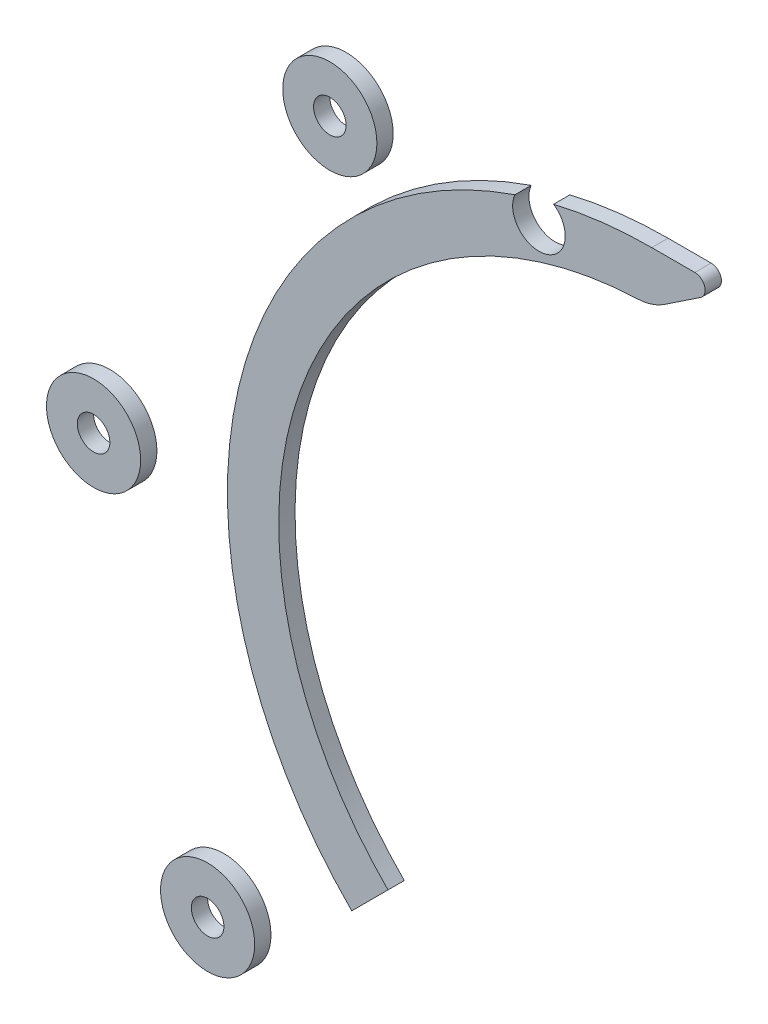
from build123d import *

# Parameters (mm, degrees)
BOSS_EXTRUDE1_DEPTH   = 3.175
SKETCH1_R             = 9.175
SKETCH1_R_2           = 3.175
BOSS_EXTRUDE1_2_DEPTH = 3.175
BOSS_EXTRUDE1_3_DEPTH = 3.175
BOSS_EXTRUDE1_4_DEPTH = 3.175
SKETCH3_R             = 5.125
CUT_EXTRUDE1_DEPTH    = 10
BOSS_EXTRUDE2_DEPTH   = 3.175
FILLET1_R             = 10
FILLET2_R             = 2


with BuildPart() as part:
    # Sketch1 → Boss-Extrude1 (new body)
    with BuildSketch(Plane.XY):
        with BuildLine():
            ThreePointArc((-51.423758408, -51.423758408), (-67.188378251, 27.830337505), (0, 72.724176569))
            Line((0, 72.724176569), (0, 82.724176569))
            ThreePointArc((0, 82.724176569), (-76.427173576, 31.657171829), (-58.49482622, -58.49482622))
            Line((-58.49482622, -58.49482622), (-51.423758408, -51.423758408))
        make_face()
    extrude(amount=-BOSS_EXTRUDE1_DEPTH)

    # Sketch3 → Cut-Extrude1 (cut)
    with BuildSketch(Plane(origin=(0, 0, -3.175), x_dir=(-1, 0, 0), z_dir=(0, 0, -1))):
        with Locations((22, 76.224176569)):
            Circle(SKETCH3_R)
    extrude(amount=-CUT_EXTRUDE1_DEPTH, mode=Mode.SUBTRACT)

    # Sketch4 → Boss-Extrude2 (add)
    with BuildSketch(Plane.XY):
        Polygon((0, 82.724176569), (15, 82.724176569), (0, 72.724176569), align=None)
    extrude(amount=-BOSS_EXTRUDE2_DEPTH)

    # Fillet1
    fillet1_edges = [part.edges().sort_by_distance(p)[0] for p in [
        (0, 72.724176569, -1.5875),
    ]]
    fillet(fillet1_edges, radius=FILLET1_R)

    # Fillet2
    fillet2_edges = [part.edges().sort_by_distance(p)[0] for p in [
        (15, 82.724176569, -1.5875),
    ]]
    fillet(fillet2_edges, radius=FILLET2_R)


with BuildPart() as body_2:
    # Sketch1 → Boss-Extrude1 2 (new body)
    with BuildSketch(Plane.XY):
        with Locations((-86.585964118, -73.610554684)):
            Circle(SKETCH1_R)
        with Locations((-86.585964118, -73.610554684)):
            Circle(SKETCH1_R_2, mode=Mode.SUBTRACT)
    extrude(amount=-BOSS_EXTRUDE1_2_DEPTH)


with BuildPart() as body_3:
    # Sketch1 → Boss-Extrude1 3 (new body)
    with BuildSketch(Plane.XY):
        with Locations((-62.763254538, 73.549176569)):
            Circle(SKETCH1_R)
        with Locations((-62.763254538, 73.549176569)):
            Circle(SKETCH1_R_2, mode=Mode.SUBTRACT)
    extrude(amount=-BOSS_EXTRUDE1_3_DEPTH)


with BuildPart() as body_4:
    # Sketch1 → Boss-Extrude1 4 (new body)
    with BuildSketch(Plane.XY):
        with Locations((-108.816589821, -3.003434316)):
            Circle(SKETCH1_R)
        with Locations((-108.816589821, -3.003434316)):
            Circle(SKETCH1_R_2, mode=Mode.SUBTRACT)
    extrude(amount=-BOSS_EXTRUDE1_4_DEPTH)


solid = Compound([part.part, body_2.part, body_3.part, body_4.part])
